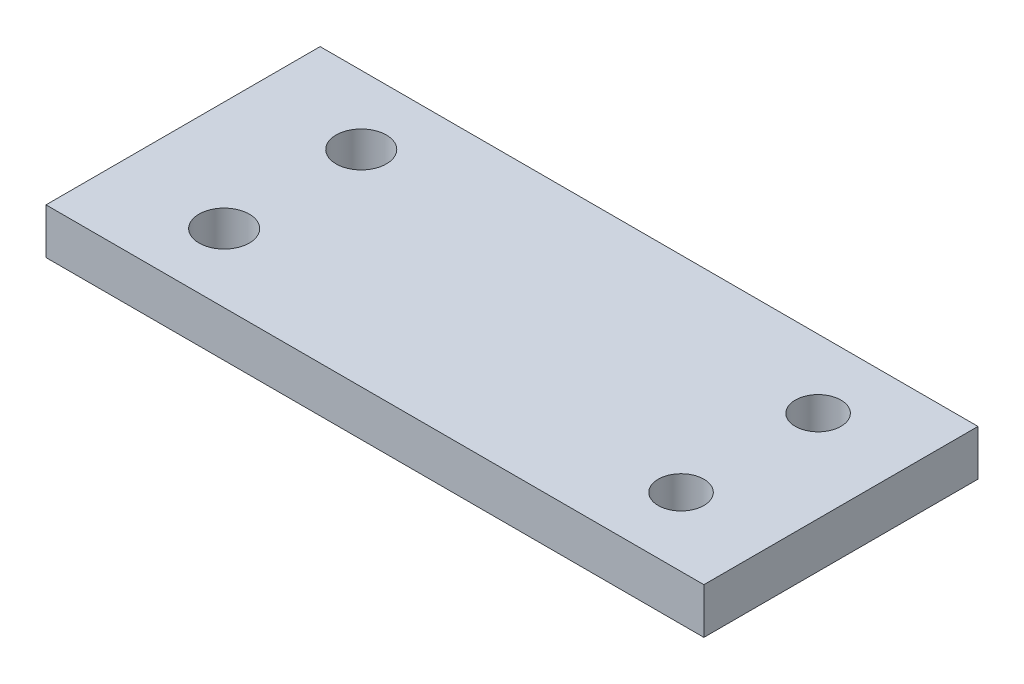
from build123d import *

# Parameters (mm, degrees)
SKETCH1_W           = 72
SKETCH1_H           = 30
BOSS_EXTRUDE1_DEPTH = 5
SKETCH3_R           = 2.75
SKETCH3_R_2         = 2.5
CUT_EXTRUDE1_DEPTH  = 6


with BuildPart() as part:
    # Sketch1 → Boss-Extrude1 (new body)
    with BuildSketch(Plane(origin=(0, 0, 0), x_dir=(1, 0, 0), z_dir=(0, 1, 0))):
        Rectangle(SKETCH1_W, SKETCH1_H)
    extrude(amount=BOSS_EXTRUDE1_DEPTH)

    # Sketch3 → Cut-Extrude1 (cut, through all)
    with BuildSketch(Plane(origin=(0, 5, 0), x_dir=(1, 0, 0), z_dir=(0, 1, 0))):
        with Locations((-24, 7.5)):
            Circle(SKETCH3_R)
        with Locations((-24, -7.5)):
            Circle(SKETCH3_R)
        with Locations((26, 7.5)):
            Circle(SKETCH3_R_2)
        with Locations((26, -7.5)):
            Circle(SKETCH3_R_2)
    extrude(amount=-CUT_EXTRUDE1_DEPTH, mode=Mode.SUBTRACT)


solid = part.part
